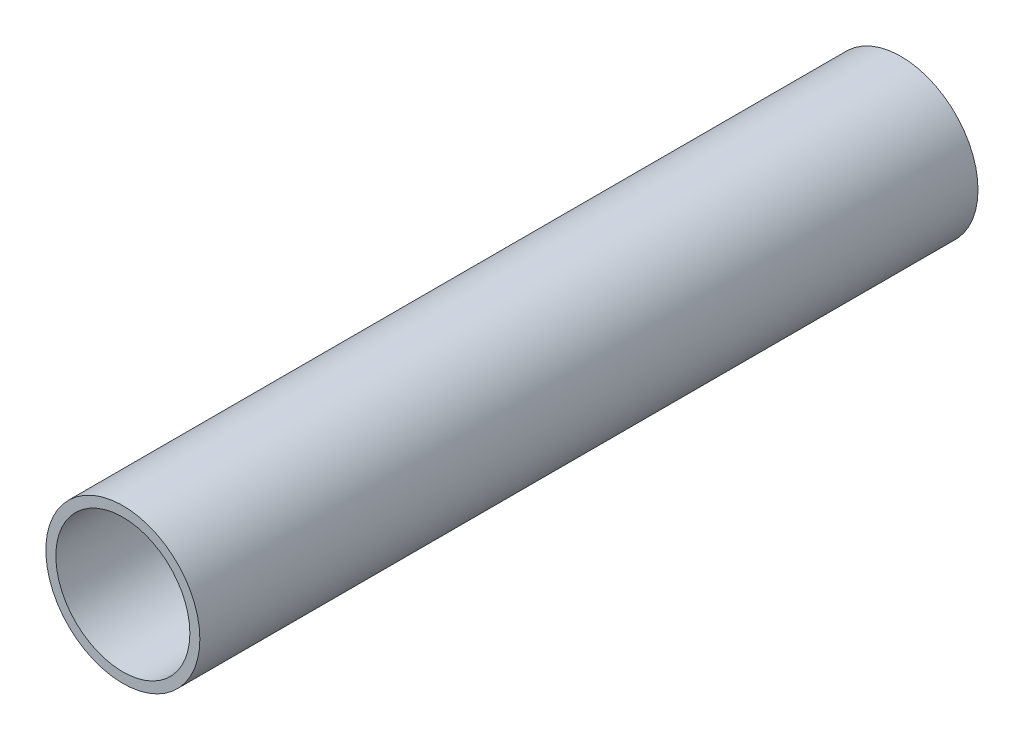
from build123d import *

# Parameters (mm, degrees)
SKETCH1_R           = 30.1625
SKETCH1_R_2         = 26.2509
BOSS_EXTRUDE1_DEPTH = 304.8


with BuildPart() as part:
    # Sketch1 → Boss-Extrude1 (new body)
    with BuildSketch(Plane.XY):
        Circle(SKETCH1_R)
        Circle(SKETCH1_R_2, mode=Mode.SUBTRACT)
    extrude(amount=BOSS_EXTRUDE1_DEPTH)


solid = part.part
